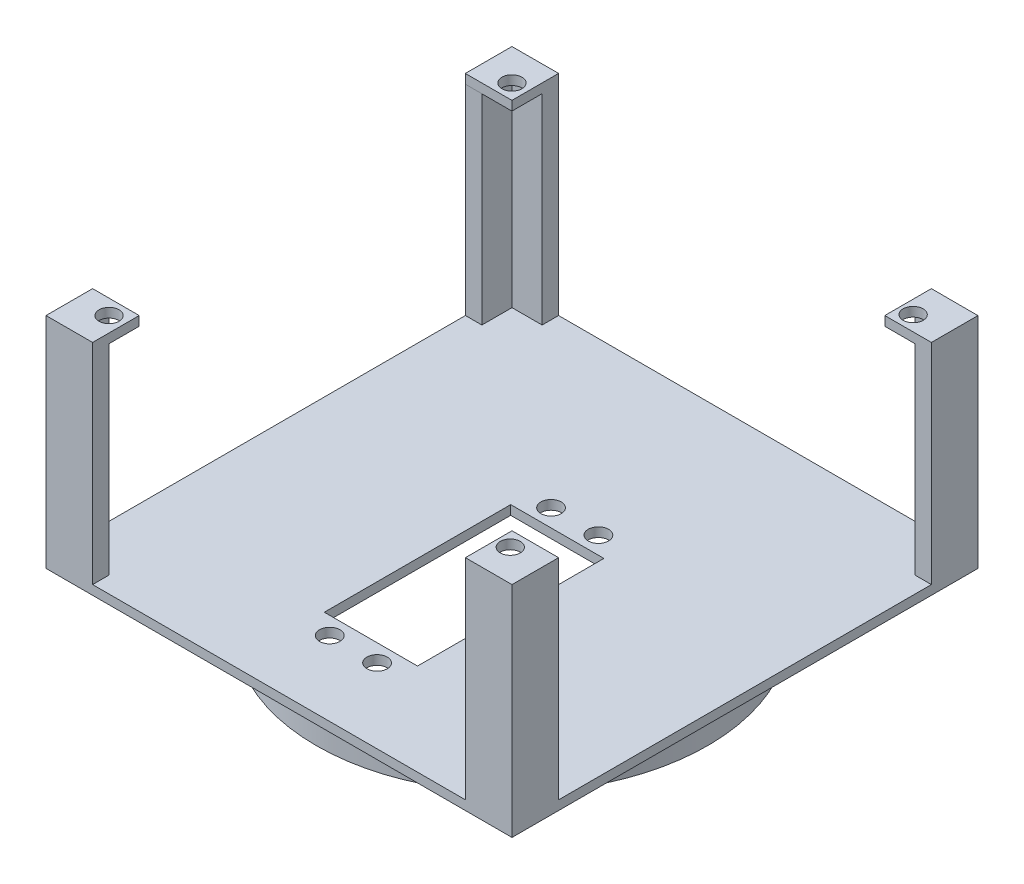
from build123d import *

# Parameters (mm, degrees)
SKETCH1_R           = 2.1844
SKETCH1_W           = 20
SKETCH1_H           = 40
BOSS_EXTRUDE1_DEPTH = 2
BOSS_EXTRUDE2_DEPTH = 45
SKETCH2_W           = 10
SKETCH2_H           = 10
SKETCH2_R           = 2.15
BOSS_EXTRUDE3_DEPTH = 2
SKETCH1_4_R         = 42
SKETCH1_4_R_2       = 40
BOSS_EXTRUDE4_DEPTH = 11.9409


with BuildPart() as part:
    # Sketch1 → Boss-Extrude1 (new body)
    with BuildSketch(Plane(origin=(0, 0, 0), x_dir=(1, 0, 0), z_dir=(0, 1, 0))):
        Polygon((-46.464466094, -60), (-46.464466094, -66.464466094), (-40, -66.464466094), (-40, -70), (40, -70), (40, -66.464466094), (46.464466094, -66.464466094), (46.464466094, -60), (50, -60), (50, 20), (46.464466094, 20), (46.464466094, 26.464466094), (40, 26.464466094), (40, 30), (-40, 30), (-40, 26.464466094), (-46.464466094, 26.464466094), (-46.464466094, 20), (-50, 20), (-50, -60), align=None)
        with Locations((5.08, -6.538)):
            Circle(SKETCH1_R, mode=Mode.SUBTRACT)
        with Locations((-5.08, -54.036)):
            Circle(SKETCH1_R, mode=Mode.SUBTRACT)
        with Locations((5.08, -54.036)):
            Circle(SKETCH1_R, mode=Mode.SUBTRACT)
        with Locations((0, -30.278699998)):
            Rectangle(SKETCH1_W, SKETCH1_H, mode=Mode.SUBTRACT)
        with Locations((-5.08, -6.538)):
            Circle(SKETCH1_R, mode=Mode.SUBTRACT)
    extrude(amount=BOSS_EXTRUDE1_DEPTH)

    # Sketch1_3 → Boss-Extrude2 (add)
    with BuildSketch(Plane(origin=(0, 0, 0), x_dir=(1, 0, 0), z_dir=(0, 1, 0))):
        Polygon((-50, -60), (-50, -70), (-40, -70), (-40, -66.464466094), (-46.464466094, -66.464466094), (-46.464466094, -60), align=None)
        Polygon((40, -66.464466094), (40, -70), (50, -70), (50, -60), (46.464466094, -60), (46.464466094, -66.464466094), align=None)
        Polygon((-50, 30), (-50, 20), (-46.464466094, 20), (-46.464466094, 26.464466094), (-40, 26.464466094), (-40, 30), align=None)
        Polygon((46.464466094, 20), (50, 20), (50, 30), (40, 30), (40, 26.464466094), (46.464466094, 26.464466094), align=None)
    extrude(amount=BOSS_EXTRUDE2_DEPTH)

    # Sketch2 → Boss-Extrude3 (add)
    # profile 1 of 4: a face of its own
    with BuildSketch(Plane(origin=(0, 45, 0), x_dir=(1, 0, 0), z_dir=(0, 1, 0))):
        with Locations((45, -65)):
            Rectangle(SKETCH2_W, SKETCH2_H)
        with Locations((42.862206079, -63.232233047)):
            Circle(SKETCH2_R, mode=Mode.SUBTRACT)
    # profile 2 of 4: a face of its own
    with BuildSketch(Plane(origin=(0, 45, 0), x_dir=(1, 0, 0), z_dir=(0, 1, 0))):
        with Locations((-45, -65)):
            Rectangle(SKETCH2_W, SKETCH2_H)
        with Locations((-43.232233047, -63.232233047)):
            Circle(SKETCH2_R, mode=Mode.SUBTRACT)
    # profile 3 of 4: a face of its own
    with BuildSketch(Plane(origin=(0, 45, 0), x_dir=(1, 0, 0), z_dir=(0, 1, 0))):
        Polygon((-50, 29.983399997), (-50, 19.983399997), (-40, 19.983399997), (-40, 30), align=None)
        with Locations((-43.232233047, 23.215633044)):
            Circle(SKETCH2_R, mode=Mode.SUBTRACT)
    # profile 4 of 4: a face of its own
    with BuildSketch(Plane(origin=(0, 45, 0), x_dir=(1, 0, 0), z_dir=(0, 1, 0))):
        Polygon((50, 29.983399997), (40, 30), (40, 20), (50, 20), align=None)
        with Locations((42.862206079, 23.215633044)):
            Circle(SKETCH2_R, mode=Mode.SUBTRACT)
    extrude(amount=BOSS_EXTRUDE3_DEPTH)


with BuildPart() as body_2:
    # Sketch1_4 → Boss-Extrude4 (new body)
    with BuildSketch(Plane(origin=(0, 0, 0), x_dir=(1, 0, 0), z_dir=(0, 1, 0))):
        with Locations((0, -20)):
            Circle(SKETCH1_4_R)
        with Locations((0, -20)):
            Circle(SKETCH1_4_R_2, mode=Mode.SUBTRACT)
    extrude(amount=-BOSS_EXTRUDE4_DEPTH)


solid = Compound([part.part, body_2.part])
